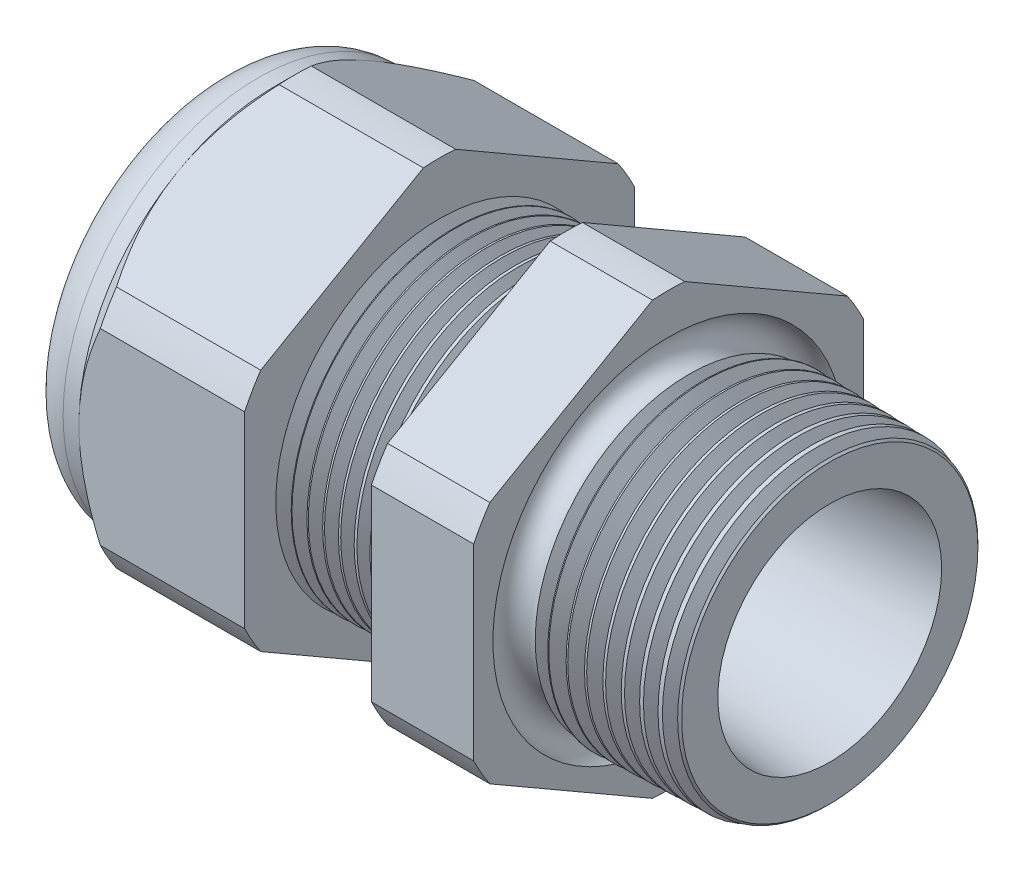
from build123d import *

# Parameters (mm, degrees)
SKETCH12_OUTSIDE_W = 52.432
SKETCH12_OUTSIDE_H = 52.432
CUT_EXTRUDE2_DEPTH = 28.172
FILLET4_R          = 2.032
SKETCH19_OUTSIDE_W = 33.316
SKETCH19_OUTSIDE_H = 35.412
SKETCH19_OUTSIDE_R = 9.525
CUT_EXTRUDE3_DEPTH = 1.999996
CUT_EXTRUDE3_DRAFT = -45
CHAMFER1_SIZE      = 0.260919487
CHAMFER1_SIZE2     = 0.254
SKETCH21_R         = 3.937
PLUG_DEPTH         = 3.81
SKETCH22_R         = 3.683
CUT_EXTRUDE4_DEPTH = 0.508
SKETCH27_R         = 1.524
PLUGHOLES_DEPTH    = 30.464
CIRPATTERN1_COUNT  = 2
LPATTERN1_COUNT    = 8
LPATTERN1_PITCH    = 0.762
LPATTERN2_COUNT    = 9
LPATTERN2_PITCH    = 0.889
SKETCH32_R         = 0.889


with BuildPart() as part:
    # Sketch10 → Revolve2 (revolve)
    with BuildSketch(Plane.XY, mode=Mode.PRIVATE) as revolve2_sk:
        Polygon((-29.972, 3.937), (-19.072, 3.937), (0, 5.469582104), (0, 7.501582104), (-7.874, 7.70777005), (-7.874, 19.05), (-12.874, 19.05), (-12.874, 7.838699658), (-19.072, 8.001), (-19.072, 19.05), (-27.172, 19.05), (-27.172, 9.525), (-29.972, 9.525), align=None)
    revolve(revolve2_sk.sketch.rotate(Axis((0, 0, 0), (-1, 0, 0)), 90), axis=Axis((0, 0, 0), (-1, 0, 0)))  # turned: the seam where the file's is

    # Sketch12 outside → Cut-Extrude2 (cut, through all)
    with BuildSketch(Plane.ZY.offset(27.172)):
        Rectangle(SKETCH12_OUTSIDE_W, SKETCH12_OUTSIDE_H)
        with BuildLine():
            Line((-0.788451287, 10.543310065), (-8.736548713, 5.954473877))
            ThreePointArc((-8.736548713, 5.954473877), (-9.156270088, 5.286375), (-9.525, 4.588836188))
            Line((-9.525, 4.588836188), (-9.525, -4.588836188))
            ThreePointArc((-9.525, -4.588836188), (-9.156270088, -5.286375), (-8.736548713, -5.954473877))
            Line((-8.736548713, -5.954473877), (-0.788451287, -10.543310065))
            ThreePointArc((-0.788451287, -10.543310065), (0, -10.57275), (0.788451287, -10.543310065))
            Line((0.788451287, -10.543310065), (8.736548713, -5.954473877))
            ThreePointArc((8.736548713, -5.954473877), (9.156270088, -5.286375), (9.525, -4.588836188))
            Line((9.525, -4.588836188), (9.525, 4.588836188))
            ThreePointArc((9.525, 4.588836188), (9.156270088, 5.286375), (8.736548713, 5.954473877))
            Line((8.736548713, 5.954473877), (0.788451287, 10.543310065))
            ThreePointArc((0.788451287, 10.543310065), (0, 10.57275), (-0.788451287, 10.543310065))
        make_face(mode=Mode.SUBTRACT)
    extrude(amount=-CUT_EXTRUDE2_DEPTH, mode=Mode.SUBTRACT)

    # Fillet4
    fillet4_edges = [part.edges().sort_by_distance(p)[0] for p in [
        (-29.972, 0, 9.525),
    ]]
    fillet(fillet4_edges, radius=FILLET4_R)


with BuildPart() as cut_extrude3_tool:
    # Sketch19 outside → Cut-Extrude3 (with draft: the straight prism first)
    with BuildSketch(Plane.ZY.offset(27.172)):
        Rectangle(SKETCH19_OUTSIDE_W, SKETCH19_OUTSIDE_H)
        Circle(SKETCH19_OUTSIDE_R, mode=Mode.SUBTRACT)
    extrude(amount=-CUT_EXTRUDE3_DEPTH)
    # Cut-Extrude3: the draft: its side faces are tilted about the plane it starts from
    cut_extrude3_sides = [cut_extrude3_tool.faces().sort_by_distance(p)[0] for p in [
        (-26.172002, -17.706, 0),
        (-26.172002, 0, 16.658),
        (-26.172002, 17.706, 0),
        (-26.172002, 0, -16.658),
        (-26.172002, 0, -9.525),
    ]]
    draft(cut_extrude3_sides, Plane.ZY.offset(27.172), CUT_EXTRUDE3_DRAFT)


with BuildPart() as part_1:
    add(part.part)

    # Cut-Extrude3: cut by cut_extrude3_tool
    add(cut_extrude3_tool.part, mode=Mode.SUBTRACT)

    # Chamfer1
    chamfer1_edges = [part_1.edges().sort_by_distance(p)[0] for p in [
        (0, 0, 7.501582104),
    ]]
    chamfer1_side = [part_1.faces().sort_by_distance(p)[0] for p in [
        (0, 0, 5.681758887),
    ]]
    chamfer(chamfer1_edges, length=CHAMFER1_SIZE, length2=CHAMFER1_SIZE2, reference=chamfer1_side[0])

    # Sketch29 → Cut-Revolve1 (revolve, cut)
    with BuildSketch(Plane.XY, mode=Mode.PRIVATE) as cut_revolve1_sk:
        Polygon((-19.072, 8.001), (-18.339016419, 7.981806149), (-18.722130572, 7.356620673), align=None)
    cut_revolve1 = revolve(cut_revolve1_sk.sketch.rotate(Axis((0, 0, 0), (-1, 0, 0)), 90), axis=Axis((0, 0, 0), (-1, 0, 0)), mode=Mode.SUBTRACT)  # turned: the seam where the file's is

    # LPattern1: Cut-Revolve1 ×8
    with Locations(*[(i * LPATTERN1_PITCH, 0, 0) for i in range(1, LPATTERN1_COUNT)]):
        add(cut_revolve1, mode=Mode.SUBTRACT)

    # Sketch30 → Cut-Revolve2 (revolve, cut)
    with BuildSketch(Plane.XY, mode=Mode.PRIVATE) as cut_revolve2_sk:
        Polygon((-7.874, 7.70777005), (-6.994419703, 7.68473743), (-7.454156686, 6.934514858), align=None)
    cut_revolve2 = revolve(cut_revolve2_sk.sketch.rotate(Axis((0, 0, 0), (-1, 0, 0)), 270), axis=Axis((0, 0, 0), (-1, 0, 0)), mode=Mode.SUBTRACT)  # turned: the seam where the file's is

    # LPattern2: Cut-Revolve2 ×9
    with Locations(*[(i * LPATTERN2_PITCH, 0, 0) for i in range(1, LPATTERN2_COUNT)]):
        add(cut_revolve2, mode=Mode.SUBTRACT)

    # Sketch32 → Cut-Revolve3 (revolve, cut)
    with BuildSketch(Plane.XY, mode=Mode.PRIVATE) as cut_revolve3_sk:
        with Locations((-7.747, 7.70777005)):
            Circle(SKETCH32_R)
    revolve(cut_revolve3_sk.sketch.rotate(Axis((0, 0, 0), (-1, 0, 0)), 270), axis=Axis((0, 0, 0), (-1, 0, 0)), mode=Mode.SUBTRACT)  # turned: the seam where the file's is


with BuildPart() as body_2:
    # Sketch21 → plug (new body)
    with BuildSketch(Plane.ZY.offset(29.972)):
        Circle(SKETCH21_R)
    extrude(amount=-PLUG_DEPTH)

    # Sketch22 → Cut-Extrude4 (cut)
    with BuildSketch(Plane.ZY.offset(29.972)):
        Circle(SKETCH22_R)
    extrude(amount=-CUT_EXTRUDE4_DEPTH, mode=Mode.SUBTRACT)

    # Sketch27 → plugholes (cut, through all)
    with BuildSketch(Plane.ZY.offset(29.464)):
        with Locations((-2.152904, 0)):
            Circle(SKETCH27_R)
    plugholes = extrude(amount=-PLUGHOLES_DEPTH, mode=Mode.SUBTRACT)

    # CirPattern1: plugholes ×2 about axis
    cirpattern1_axis = Axis((0, 0, 0), (1, 0, 0))
    for i in range(1, CIRPATTERN1_COUNT):
        add(plugholes.rotate(cirpattern1_axis, i * 360 / CIRPATTERN1_COUNT), mode=Mode.SUBTRACT)


solid = Compound([part_1.part, body_2.part])
